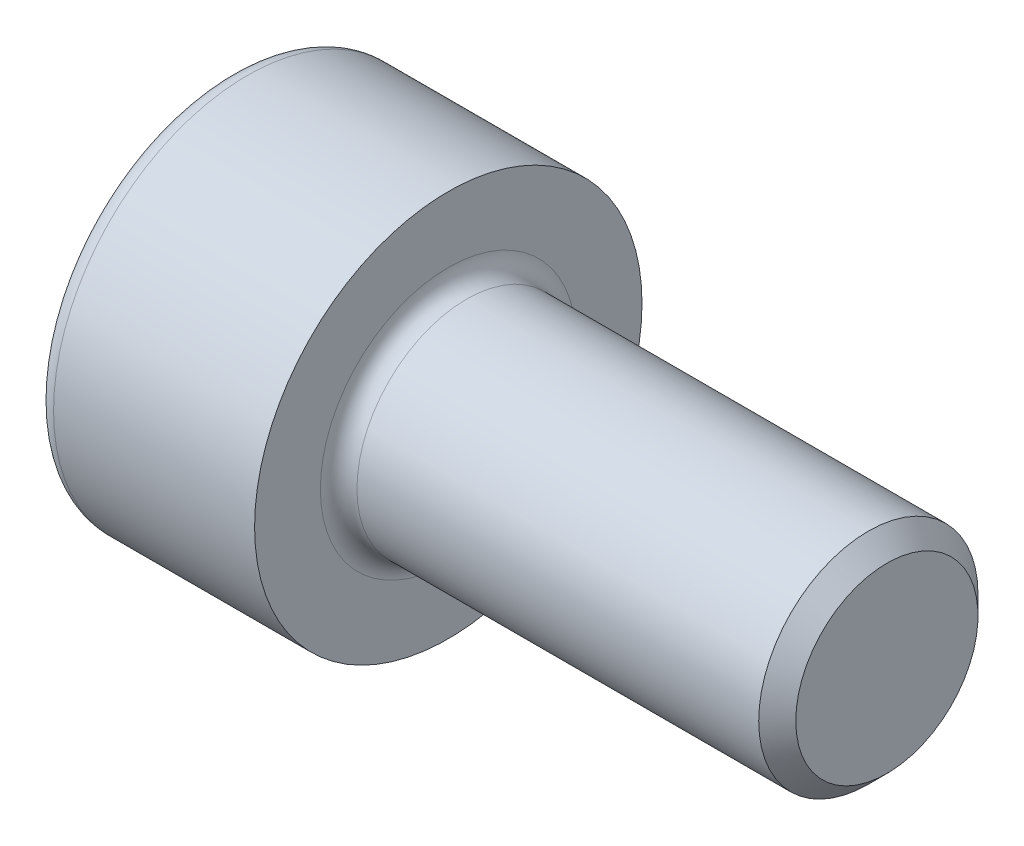
from build123d import *

# Parameters (mm, degrees)
CUT_EXTRUDE1_DEPTH = 1.1


with BuildPart() as part:
    # Sketch1 → Revolve1 (revolve)
    with BuildSketch(Plane.XY):
        with BuildLine():
            Line((5.7465, 1.5), (0.25, 1.5))
            ThreePointArc((0.25, 1.5), (0.073223305, 1.573223305), (0, 1.75))
            Line((0, 1.75), (0, 2.65))
            Line((0, 2.65), (-2.75, 2.65))
            ThreePointArc((-2.75, 2.65), (-2.926776695, 2.576776695), (-3, 2.4))
            Line((-3, 2.4), (-3, 0))
            Line((-3, 0), (6, 0))
            Line((6, 0), (6, 1.2465))
            Line((6, 1.2465), (5.7465, 1.5))
        make_face()
    revolve(axis=Axis((-3, 0, 0), (1, 0, 0)))

    # Sketch2 → Cut-Extrude1 (cut)
    with BuildSketch(Plane.ZY.offset(3)):
        Polygon((0.75, 0.433012702), (0, 0.866025404), (-0.75, 0.433012702), (-0.75, -0.433012702), (0, -0.866025404), (0.75, -0.433012702), align=None)
    extrude(amount=-CUT_EXTRUDE1_DEPTH, mode=Mode.SUBTRACT)


solid = part.part
